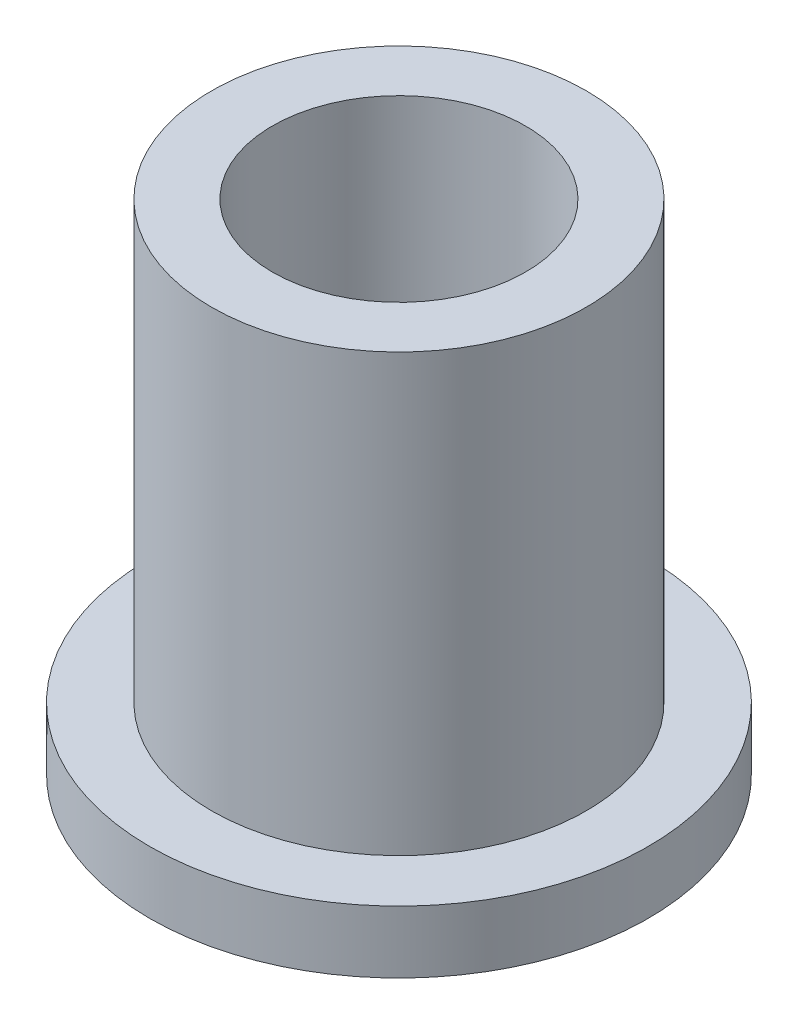
from build123d import *

# Parameters (mm, degrees)
SKETCH2_R           = 4.7752
SKETCH2_R_2         = 3.2258
BOSS_EXTRUDE1_DEPTH = 12.7
SKETCH3_R           = 6.35
SKETCH3_R_2         = 4.7752
BOSS_EXTRUDE2_DEPTH = 1.5875


with BuildPart() as part:
    # Sketch2 → Boss-Extrude1 (new body)
    with BuildSketch(Plane(origin=(0, 0, 0), x_dir=(1, 0, 0), z_dir=(0, 1, 0))):
        Circle(SKETCH2_R)
        Circle(SKETCH2_R_2, mode=Mode.SUBTRACT)
    extrude(amount=BOSS_EXTRUDE1_DEPTH)

    # Sketch3 → Boss-Extrude2 (add)
    with BuildSketch(Plane(origin=(0, 0, 0), x_dir=(1, 0, 0), z_dir=(0, 1, 0))):
        Circle(SKETCH3_R)
        Circle(SKETCH3_R_2, mode=Mode.SUBTRACT)
    extrude(amount=BOSS_EXTRUDE2_DEPTH)


solid = part.part
